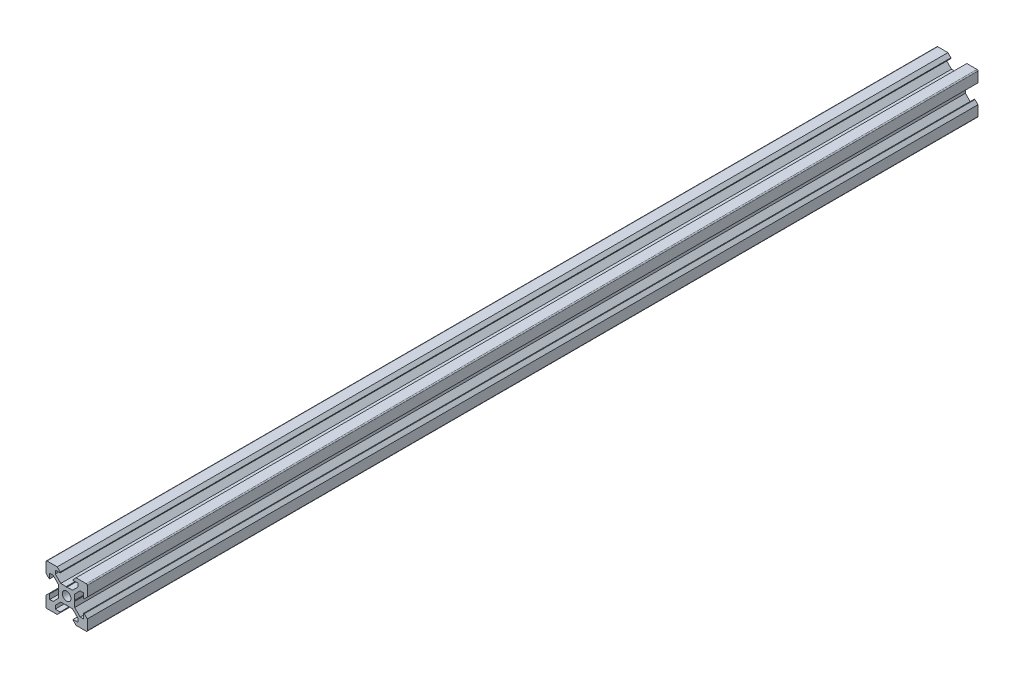
from build123d import *

# Parameters (mm, degrees)
SKETCH1_R                 = 2.1
BOSS_EXTRUDE1_DEPTH       = 500
M5X0_8_TAPPED_HOLE1_D     = 4.2
M5X0_8_TAPPED_HOLE1_DEPTH = 13.97
M5X0_8_TAPPED_HOLE1_TIP   = 1.2618073
M5X0_8_TAPPED_HOLE2_D     = 4.2
M5X0_8_TAPPED_HOLE2_DEPTH = 13.97
M5X0_8_TAPPED_HOLE2_TIP   = 1.2618073


with BuildPart() as part:
    # Sketch1 → Boss-Extrude1 (new body)
    with BuildSketch(Plane(origin=(0, 0, 0), x_dir=(-1, 0, 0), z_dir=(0, 0, -1))):
        with BuildLine():
            Line((-3.9, -0.21), (-3.9, -2.839339828))
            Line((-3.9, -2.839339828), (-6.560660172, -5.5))
            Line((-6.560660172, -5.5), (-8.2, -5.5))
            Line((-8.2, -5.5), (-8.2, -3.125))
            Line((-8.2, -3.125), (-8.545, -3.125))
            Line((-8.545, -3.125), (-10, -4.58))
            Line((-10, -4.58), (-10, -9.5))
            ThreePointArc((-10, -9.5), (-9.853553391, -9.853553391), (-9.5, -10))
            Line((-9.5, -10), (-4.58, -10))
            Line((-4.58, -10), (-3.125, -8.545))
            Line((-3.125, -8.545), (-3.125, -8.2))
            Line((-3.125, -8.2), (-5.5, -8.2))
            Line((-5.5, -8.2), (-5.5, -6.560660172))
            Line((-5.5, -6.560660172), (-2.839339828, -3.9))
            Line((-2.839339828, -3.9), (-0.21, -3.9))
            Line((-0.21, -3.9), (0, -3.69))
            Line((0, -3.69), (0.21, -3.9))
            Line((0.21, -3.9), (2.839339828, -3.9))
            Line((2.839339828, -3.9), (5.5, -6.560660172))
            Line((5.5, -6.560660172), (5.5, -8.2))
            Line((5.5, -8.2), (3.125, -8.2))
            Line((3.125, -8.2), (3.125, -8.545))
            Line((3.125, -8.545), (4.58, -10))
            Line((4.58, -10), (9.5, -10))
            ThreePointArc((9.5, -10), (9.853553391, -9.853553391), (10, -9.5))
            Line((10, -9.5), (10, -4.58))
            Line((10, -4.58), (8.545, -3.125))
            Line((8.545, -3.125), (8.2, -3.125))
            Line((8.2, -3.125), (8.2, -5.5))
            Line((8.2, -5.5), (6.560660172, -5.5))
            Line((6.560660172, -5.5), (3.9, -2.839339828))
            Line((3.9, -2.839339828), (3.9, -0.21))
            Line((3.9, -0.21), (3.69, 0))
            Line((3.69, 0), (3.9, 0.21))
            Line((3.9, 0.21), (3.9, 2.839339828))
            Line((3.9, 2.839339828), (6.560660172, 5.5))
            Line((6.560660172, 5.5), (8.2, 5.5))
            Line((8.2, 5.5), (8.2, 3.125))
            Line((8.2, 3.125), (8.545, 3.125))
            Line((8.545, 3.125), (10, 4.58))
            Line((10, 4.58), (10, 9.5))
            ThreePointArc((10, 9.5), (9.853553391, 9.853553391), (9.5, 10))
            Line((9.5, 10), (4.58, 10))
            Line((4.58, 10), (3.125, 8.545))
            Line((3.125, 8.545), (3.125, 8.2))
            Line((3.125, 8.2), (5.5, 8.2))
            Line((5.5, 8.2), (5.5, 6.560660172))
            Line((5.5, 6.560660172), (2.839339828, 3.9))
            Line((2.839339828, 3.9), (0.21, 3.9))
            Line((0.21, 3.9), (0, 3.69))
            Line((0, 3.69), (-0.21, 3.9))
            Line((-0.21, 3.9), (-2.839339828, 3.9))
            Line((-2.839339828, 3.9), (-5.5, 6.560660172))
            Line((-5.5, 6.560660172), (-5.5, 8.2))
            Line((-5.5, 8.2), (-3.125, 8.2))
            Line((-3.125, 8.2), (-3.125, 8.545))
            Line((-3.125, 8.545), (-4.58, 10))
            Line((-4.58, 10), (-9.5, 10))
            ThreePointArc((-9.5, 10), (-9.853553391, 9.853553391), (-10, 9.5))
            Line((-10, 9.5), (-10, 4.58))
            Line((-10, 4.58), (-8.545, 3.125))
            Line((-8.545, 3.125), (-8.2, 3.125))
            Line((-8.2, 3.125), (-8.2, 5.5))
            Line((-8.2, 5.5), (-6.560660172, 5.5))
            Line((-6.560660172, 5.5), (-3.9, 2.839339828))
            Line((-3.9, 2.839339828), (-3.9, 0.21))
            Line((-3.9, 0.21), (-3.69, 0))
            Line((-3.69, 0), (-3.9, -0.21))
        make_face()
        Circle(SKETCH1_R, mode=Mode.SUBTRACT)
    extrude(amount=-BOSS_EXTRUDE1_DEPTH)

    # Split1
    split(bisect_by=Plane.XY.offset(68.2), keep=Keep.TOP)

    # M5x0.8 Tapped Hole1
    with Locations(Plane.XY.offset(500)):
        with Locations((0, 0)):
            Hole(M5X0_8_TAPPED_HOLE1_D / 2, depth=M5X0_8_TAPPED_HOLE1_DEPTH)
            with Locations((0, 0, -(M5X0_8_TAPPED_HOLE1_DEPTH + M5X0_8_TAPPED_HOLE1_TIP / 2))):  # 118° drill point
                Cone(0, M5X0_8_TAPPED_HOLE1_D / 2, M5X0_8_TAPPED_HOLE1_TIP, mode=Mode.SUBTRACT)

    # M5x0.8 Tapped Hole2
    with Locations(Plane(origin=(0, 0, 68.2), x_dir=(-1, 0, 0), z_dir=(0, 0, -1))):
        with Locations((0, 0)):
            Hole(M5X0_8_TAPPED_HOLE2_D / 2, depth=M5X0_8_TAPPED_HOLE2_DEPTH)
            with Locations((0, 0, -(M5X0_8_TAPPED_HOLE2_DEPTH + M5X0_8_TAPPED_HOLE2_TIP / 2))):  # 118° drill point
                Cone(0, M5X0_8_TAPPED_HOLE2_D / 2, M5X0_8_TAPPED_HOLE2_TIP, mode=Mode.SUBTRACT)


solid = part.part
